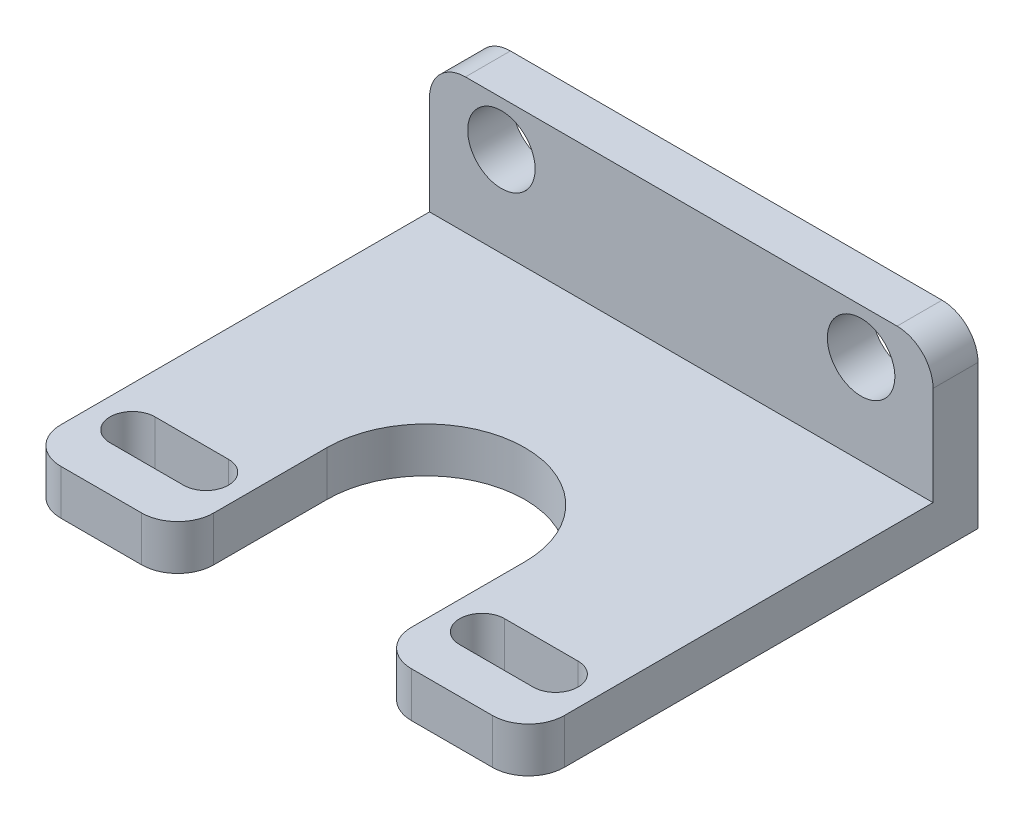
from build123d import *

# Parameters (mm, degrees)
SKETCH1_W           = 35.56
SKETCH1_H           = 12.7
SKETCH1_R           = 2.38125
BOSS_EXTRUDE1_DEPTH = 3.175
SKETCH7_W           = 35.56
SKETCH7_H           = 3.175
BOSS_EXTRUDE3_DEPTH = 28.575
CUT_EXTRUDE6_DEPTH  = 28.575
FILLET3_R           = 2.54


with BuildPart() as part:
    # Sketch1 → Boss-Extrude1 (new body)
    with BuildSketch(Plane.XY):
        Rectangle(SKETCH1_W, SKETCH1_H)
        with Locations((-12.7, 3.175)):
            Circle(SKETCH1_R, mode=Mode.SUBTRACT)
        with Locations((12.7, 3.175)):
            Circle(SKETCH1_R, mode=Mode.SUBTRACT)
    extrude(amount=BOSS_EXTRUDE1_DEPTH)

    # Sketch7 → Boss-Extrude3 (add)
    with BuildSketch(Plane.XY.offset(3.175)):
        with Locations((0, -4.7625)):
            Rectangle(SKETCH7_W, SKETCH7_H)
    extrude(amount=BOSS_EXTRUDE3_DEPTH)

    # Sketch11 → Cut-Extrude6 (cut)
    with BuildSketch(Plane.XZ.offset(6.35)):
        with BuildLine():
            Line((-6.985, 42.291890454), (6.985, 42.291890454))
            Line((6.985, 42.291890454), (6.985, 21.208109546))
            ThreePointArc((6.985, 21.208109546), (0, 14.223109546), (-6.985, 21.208109546))
            Line((-6.985, 21.208109546), (-6.985, 42.291890454))
        make_face()
        with BuildLine():
            Line((-14.938781825, 28.575), (-9.750668862, 28.575))
            ThreePointArc((-9.750668862, 28.575), (-8.163168862, 26.9875), (-9.750668862, 25.4))
            Line((-9.750668862, 25.4), (-14.938781825, 25.4))
            ThreePointArc((-14.938781825, 25.4), (-16.526281825, 26.9875), (-14.938781825, 28.575))
        make_face()
        with BuildLine():
            Line((14.938781825, 28.575), (9.750668862, 28.575))
            ThreePointArc((9.750668862, 28.575), (8.163168862, 26.9875), (9.750668862, 25.4))
            Line((9.750668862, 25.4), (14.938781825, 25.4))
            ThreePointArc((14.938781825, 25.4), (16.526281825, 26.9875), (14.938781825, 28.575))
        make_face()
    extrude(amount=-CUT_EXTRUDE6_DEPTH, mode=Mode.SUBTRACT)

    # Fillet3
    fillet3_edges = [part.edges().sort_by_distance(p)[0] for p in [
        (6.985, -4.7625, 31.75),
        (17.78, -4.7625, 31.75),
        (-6.985, -4.7625, 31.75),
        (-17.78, -4.7625, 31.75),
        (-17.78, 6.35, 1.5875),
        (17.78, 6.35, 1.5875),
    ]]
    fillet(fillet3_edges, radius=FILLET3_R)


solid = part.part
